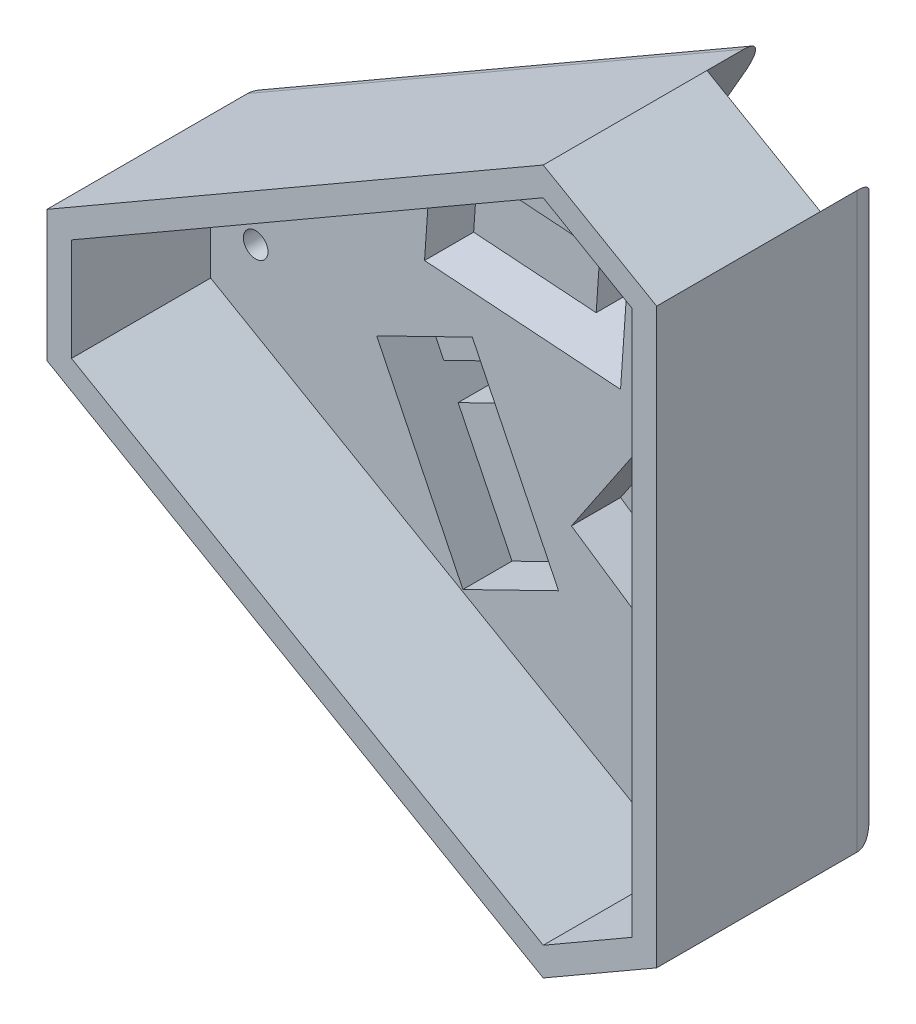
from build123d import *

# Parameters (mm, degrees)
BOSS_EXTRUDE1_DEPTH = 28
SKETCH3_W           = 16
SKETCH3_H           = 8
CUT_EXTRUDE1_DEPTH  = 12
SKETCH4_W           = 8
SKETCH4_H           = 16
CUT_EXTRUDE2_DEPTH  = 12
SKETCH5_W           = 16
SKETCH5_H           = 8
CUT_EXTRUDE3_DEPTH  = 12
SKETCH6_R           = 1.5
CUT_EXTRUDE4_DEPTH  = 66.398776747
CUT_EXTRUDE5_DEPTH  = 17
CUT_EXTRUDE6_DEPTH  = 6
CUT_EXTRUDE7_DEPTH  = 67.377707101
CIRPATTERN1_COUNT   = 3
SKETCH11_R          = 1
CUT_EXTRUDE8_DEPTH  = 10
CIRPATTERN2_COUNT   = 3
FILLET1_R           = 3.5


with BuildPart() as part:
    # Sketch1 → Boss-Extrude1 (new body)
    with BuildSketch(Plane.XY):
        Polygon((-45.033320997, -8), (-45.033320997, 8), (15.588457268, 43), (29.444863729, 35), (29.444863729, -35), (15.588457268, -43), align=None)
    extrude(amount=BOSS_EXTRUDE1_DEPTH)

    # Sketch3 → Cut-Extrude1 (cut)
    with BuildSketch(Plane(origin=(22.516660498, 39, 0), x_dir=(0.8660254037844403, -0.49999999999999717, 0), z_dir=(0.49999999999999717, 0.8660254037844403, 0))):
        with Locations((0, -4)):
            Rectangle(SKETCH3_W, SKETCH3_H)
    extrude(amount=-CUT_EXTRUDE1_DEPTH, mode=Mode.SUBTRACT)

    # Sketch4 → Cut-Extrude2 (cut)
    with BuildSketch(Plane.ZY.offset(45.033320997)):
        with Locations((4, 0)):
            Rectangle(SKETCH4_W, SKETCH4_H)
    extrude(amount=-CUT_EXTRUDE2_DEPTH, mode=Mode.SUBTRACT)

    # Sketch5 → Cut-Extrude3 (cut)
    with BuildSketch(Plane(origin=(22.516660498, -39, 0), x_dir=(0.8660254037844353, 0.5000000000000059, 0), z_dir=(0.5000000000000059, -0.8660254037844353, 0))):
        with Locations((0, 4)):
            Rectangle(SKETCH5_W, SKETCH5_H)
    extrude(amount=-CUT_EXTRUDE3_DEPTH, mode=Mode.SUBTRACT)

    # Sketch6 → Cut-Extrude4 (cut, through all)
    with BuildSketch(Plane(origin=(0, 0, 8), x_dir=(-1, 0, 0), z_dir=(0, 0, -1))):
        with Locations((-18.266660498, -31.638784068)):
            Circle(SKETCH6_R)
        with Locations((-18.266660498, 31.638784068)):
            Circle(SKETCH6_R)
        with Locations((36.533320997, 0)):
            Circle(SKETCH6_R)
    extrude(amount=-CUT_EXTRUDE4_DEPTH, mode=Mode.SUBTRACT)

    # Sketch7 → Cut-Extrude5 (cut)
    with BuildSketch(Plane.XY.offset(28)):
        Polygon((-42.033320997, -6.267949192), (-42.033320997, 6.267949192), (15.588457268, 39.535898385), (26.444863729, 33.267949192), (26.444863729, -33.267949192), (15.588457268, -39.535898385), align=None)
    extrude(amount=-CUT_EXTRUDE5_DEPTH, mode=Mode.SUBTRACT)

    # Sketch8 → Cut-Extrude6 (cut)
    with BuildSketch(Plane.XY.offset(11)):
        Polygon((-11.21880666, -23.805784253), (-21.750841765, -2.24015798), (-10.069460868, 3.464694369), (0.462574238, -18.100931904), align=None)
    cut_extrude6 = extrude(amount=-CUT_EXTRUDE6_DEPTH, mode=Mode.SUBTRACT)

    # Sketch9 → Cut-Extrude7 (cut, through all)
    with BuildSketch(Plane.XY.offset(5)):
        Polygon((-19.556667785, -6.732996787), (-7.875286887, -1.028144438), (-6.119947703, -4.622415484), (-17.801328601, -10.327267832), align=None)
    cut_extrude7 = extrude(amount=-CUT_EXTRUDE7_DEPTH, mode=Mode.SUBTRACT)

    # CirPattern1: Cut-Extrude6, Cut-Extrude7 ×3 about axis
    cirpattern1_axis = Axis((0, 0, 0), (0, 0, 1))
    add([cut_extrude6.rotate(cirpattern1_axis, i * 360 / CIRPATTERN1_COUNT) for i in range(1, CIRPATTERN1_COUNT)], mode=Mode.SUBTRACT)
    add([cut_extrude7.rotate(cirpattern1_axis, i * 360 / CIRPATTERN1_COUNT) for i in range(1, CIRPATTERN1_COUNT)], mode=Mode.SUBTRACT)

    # Sketch11 → Cut-Extrude8 (cut)
    with BuildSketch(Plane.ZY.offset(33.033320997)):
        with Locations((4.5, 4.25)):
            Circle(SKETCH11_R)
        with Locations((4.5, -4.25)):
            Circle(SKETCH11_R)
    cut_extrude8 = extrude(amount=-CUT_EXTRUDE8_DEPTH, mode=Mode.SUBTRACT)

    # CirPattern2: Cut-Extrude8 ×3 about axis
    cirpattern2_axis = Axis((0, 0, 0), (0, 0, 1))
    for i in range(1, CIRPATTERN2_COUNT):
        add(cut_extrude8.rotate(cirpattern2_axis, i * 360 / CIRPATTERN2_COUNT), mode=Mode.SUBTRACT)

    # Fillet1
    fillet1_edges = [part.edges().sort_by_distance(p)[0] for p in [
        (-14.722431864, -25.5, 0),
        (-14.722431864, 25.5, 0),
        (29.444863729, 0, 0),
    ]]
    fillet(fillet1_edges, radius=FILLET1_R)


solid = part.part
